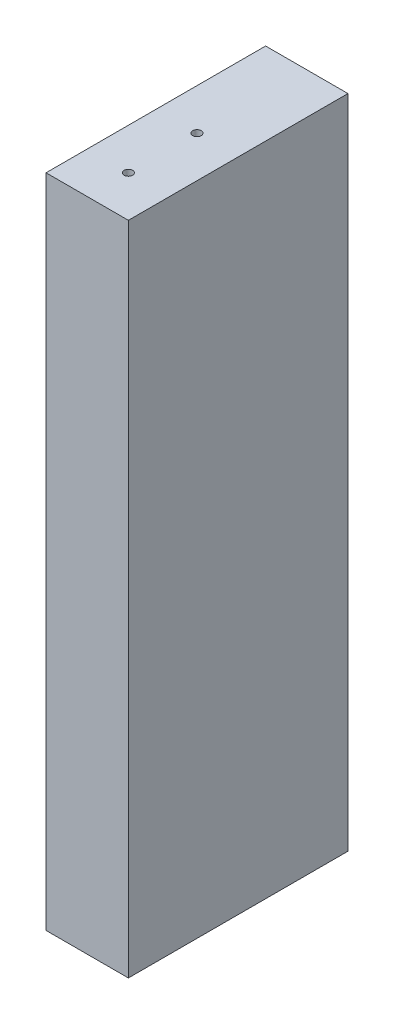
from build123d import *

# Parameters (mm, degrees)
SKETCH1_W                           = 19.05
SKETCH1_H                           = 151.8158
BOSS_EXTRUDE1_DEPTH                 = 50.8
F_5_64_0_07813_DIAMETER_HOLE1_D     = 1.984502
F_5_64_0_07813_DIAMETER_HOLE1_DEPTH = 38.1
F_5_64_0_07813_DIAMETER_HOLE1_TIP   = 0.59620455
F_5_64_0_07813_DIAMETER_HOLE2_D     = 1.984502
F_5_64_0_07813_DIAMETER_HOLE2_DEPTH = 38.1
F_5_64_0_07813_DIAMETER_HOLE2_TIP   = 0.59620455
F_5_64_0_07813_DIAMETER_HOLE3_D     = 1.984502
F_5_64_0_07813_DIAMETER_HOLE3_DEPTH = 19.05
F_5_64_0_07813_DIAMETER_HOLE3_TIP   = 0.59620455
F_5_64_0_07813_DIAMETER_HOLE4_D     = 1.984502
F_5_64_0_07813_DIAMETER_HOLE4_DEPTH = 19.05
F_5_64_0_07813_DIAMETER_HOLE4_TIP   = 0.59620455


with BuildPart() as part:
    # Sketch1 → Boss-Extrude1 (new body)
    with BuildSketch(Plane.XY):
        with Locations((452.446826131, 6526.2379)):
            Rectangle(SKETCH1_W, SKETCH1_H)
    extrude(amount=BOSS_EXTRUDE1_DEPTH)

    # 5/64 (0.07813) Diameter Hole1
    with Locations(Plane(origin=(5.615513709, 0, -19.05), x_dir=(-1, 0, 0), z_dir=(0, 0, -1))):
        with Locations((-481.589248274, 6993.254992531), (-386.339248274, 6993.254992531), (-291.089248274, 6993.254992531), (-295.274999999, 6965.135938475), (-295.274999999, 6812.735938475), (-295.274999999, 6660.335938474), (-285.166362357, 6631.468843414), (-475.477307398, 6631.468752771), (-485.002307398, 6660.335938474), (-485.002307398, 6812.735938474), (-485.002307398, 6965.135938474), (-478.365617646, 6611.6708), (-287.865617646, 6611.6708), (-307.975, 6564.3379), (-307.975, 6488.1379), (-284.960913066, 6440.805), (-380.210913066, 6440.805), (-475.460913066, 6440.805), (-446.831312422, 6488.1379), (-446.831312422, 6564.3379), (-472.231312422, 6396.355), (-472.231312422, 6320.155), (-472.653156211, 6275.705000839), (-377.403156211, 6275.705000839), (-282.153156211, 6275.705000839), (-282.575, 6320.155), (-282.575, 6396.355), (-435.598646187, 6221.729999816), (-435.598646187, 6145.529999816), (-450.592518112, 6091.554999951), (-460.998646187, 6091.555478285), (-460.998646187, 6056.629999944), (-460.998646187, 5980.429999944), (-460.998646187, 5945.505000042), (-282.153156211, 5945.505000042), (-368.611823093, 5945.505000042)):
            Hole(F_5_64_0_07813_DIAMETER_HOLE1_D / 2, depth=F_5_64_0_07813_DIAMETER_HOLE1_DEPTH)
            with Locations((0, 0, -(F_5_64_0_07813_DIAMETER_HOLE1_DEPTH + F_5_64_0_07813_DIAMETER_HOLE1_TIP / 2))):  # 118° drill point
                Cone(0, F_5_64_0_07813_DIAMETER_HOLE1_D / 2, F_5_64_0_07813_DIAMETER_HOLE1_TIP, mode=Mode.SUBTRACT)

    # 5/64 (0.07813) Diameter Hole2
    with Locations(Plane(origin=(144.471826131, 0, -19.05), x_dir=(-1, 0, 0), z_dir=(0, 0, -1))):
        with Locations((-481.589248274, 6993.254992531), (-386.339248274, 6993.254992531), (-291.089248274, 6993.254992531), (-295.274999999, 6965.135938475), (-295.274999999, 6812.735938475), (-295.274999999, 6660.335938474), (-285.166362357, 6631.468843414), (-475.477307398, 6631.468752771), (-485.002307398, 6660.335938474), (-485.002307398, 6812.735938474), (-485.002307398, 6965.135938474), (-478.365617646, 6611.6708), (-287.865617646, 6611.6708), (-307.975, 6564.3379), (-307.975, 6488.1379), (-284.960913066, 6440.805), (-380.210913066, 6440.805), (-475.460913066, 6440.805), (-446.831312422, 6488.1379), (-446.831312422, 6564.3379), (-472.231312422, 6396.355), (-472.231312422, 6320.155), (-472.653156211, 6275.705000839), (-377.403156211, 6275.705000839), (-282.153156211, 6275.705000839), (-282.575, 6320.155), (-282.575, 6396.355), (-435.598646187, 6221.729999816), (-435.598646187, 6145.529999816), (-450.592518112, 6091.554999951), (-460.998646187, 6091.555478285), (-460.998646187, 6056.629999944), (-460.998646187, 5980.429999944), (-460.998646187, 5945.505000042), (-282.153156211, 5945.505000042), (-368.611823093, 5945.505000042)):
            Hole(F_5_64_0_07813_DIAMETER_HOLE2_D / 2, depth=F_5_64_0_07813_DIAMETER_HOLE2_DEPTH)
            with Locations((0, 0, -(F_5_64_0_07813_DIAMETER_HOLE2_DEPTH + F_5_64_0_07813_DIAMETER_HOLE2_TIP / 2))):  # 118° drill point
                Cone(0, F_5_64_0_07813_DIAMETER_HOLE2_D / 2, F_5_64_0_07813_DIAMETER_HOLE2_TIP, mode=Mode.SUBTRACT)

    # 5/64 (0.07813) Diameter Hole3
    with Locations(Plane(origin=(0, 6602.1458, 0), x_dir=(1, 0, 0), z_dir=(0, 1, 0))):
        with Locations((452.446826131, -41.275), (452.446826131, -25.4)):
            Hole(F_5_64_0_07813_DIAMETER_HOLE3_D / 2, depth=F_5_64_0_07813_DIAMETER_HOLE3_DEPTH)
            with Locations((0, 0, -(F_5_64_0_07813_DIAMETER_HOLE3_DEPTH + F_5_64_0_07813_DIAMETER_HOLE3_TIP / 2))):  # 118° drill point
                Cone(0, F_5_64_0_07813_DIAMETER_HOLE3_D / 2, F_5_64_0_07813_DIAMETER_HOLE3_TIP, mode=Mode.SUBTRACT)

    # 5/64 (0.07813) Diameter Hole4
    with Locations(Plane(origin=(0, 6450.33, 0), x_dir=(-1, 0, 0), z_dir=(0, -1, 0))):
        with Locations((-452.446826131, -41.275), (-452.446826131, -25.4)):
            Hole(F_5_64_0_07813_DIAMETER_HOLE4_D / 2, depth=F_5_64_0_07813_DIAMETER_HOLE4_DEPTH)
            with Locations((0, 0, -(F_5_64_0_07813_DIAMETER_HOLE4_DEPTH + F_5_64_0_07813_DIAMETER_HOLE4_TIP / 2))):  # 118° drill point
                Cone(0, F_5_64_0_07813_DIAMETER_HOLE4_D / 2, F_5_64_0_07813_DIAMETER_HOLE4_TIP, mode=Mode.SUBTRACT)


solid = part.part
